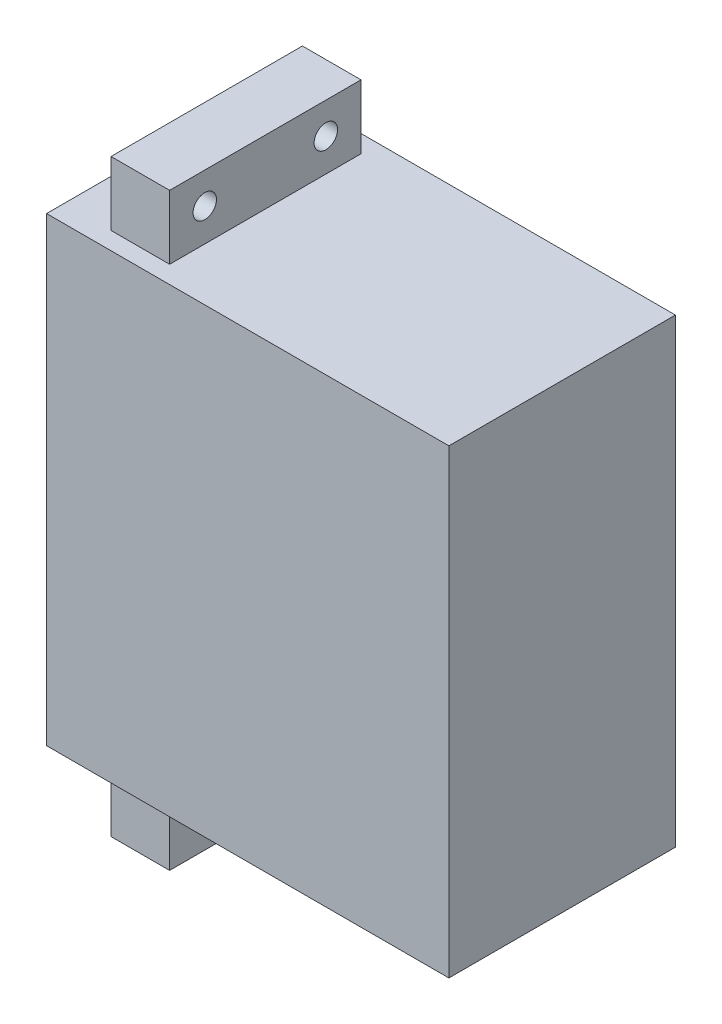
from build123d import *

# Parameters (mm, degrees)
SKETCH1_W           = 51.5
SKETCH1_H           = 59
BOSS_EXTRUDE1_DEPTH = 29
SKETCH2_W           = 7.5
SKETCH2_H           = 24.5
BOSS_EXTRUDE3_DEPTH = 8.2
SKETCH7_R           = 1.5
CUT_EXTRUDE1_DEPTH  = 8.2
SKETCH8_R           = 1.5
BOSS_EXTRUDE4_DEPTH = 2


with BuildPart() as part:
    # Sketch1 → Boss-Extrude1 (new body)
    with BuildSketch(Plane.XY):
        with Locations((25.75, 29.5)):
            Rectangle(SKETCH1_W, SKETCH1_H)
    extrude(amount=BOSS_EXTRUDE1_DEPTH)

    # Sketch2 → Boss-Extrude3 (add)
    with BuildSketch(Plane(origin=(0, 59, 0), x_dir=(1, 0, 0), z_dir=(0, 1, 0))):
        with Locations((9.75, -14.5)):
            Rectangle(SKETCH2_W, SKETCH2_H)
    boss_extrude3 = extrude(amount=BOSS_EXTRUDE3_DEPTH)

    # Sketch7 → Cut-Extrude1 (cut)
    with BuildSketch(Plane.ZY.offset(-6)):
        with Locations((6.75, 63.2)):
            Circle(SKETCH7_R)
        with Locations((22.25, 63.2)):
            Circle(SKETCH7_R)
    cut_extrude1 = extrude(amount=-CUT_EXTRUDE1_DEPTH, mode=Mode.SUBTRACT)

    # Mirror3: Boss-Extrude3, Cut-Extrude1 across plane
    add(boss_extrude3.mirror(Plane.ZX.offset(29.5)))
    add(cut_extrude1.mirror(Plane.ZX.offset(29.5)), mode=Mode.SUBTRACT)

    # Sketch8 → Boss-Extrude4 (add)
    with BuildSketch(Plane.ZY):
        with Locations((14.5, 43.7)):
            Circle(SKETCH8_R)
    extrude(amount=BOSS_EXTRUDE4_DEPTH)


solid = part.part
